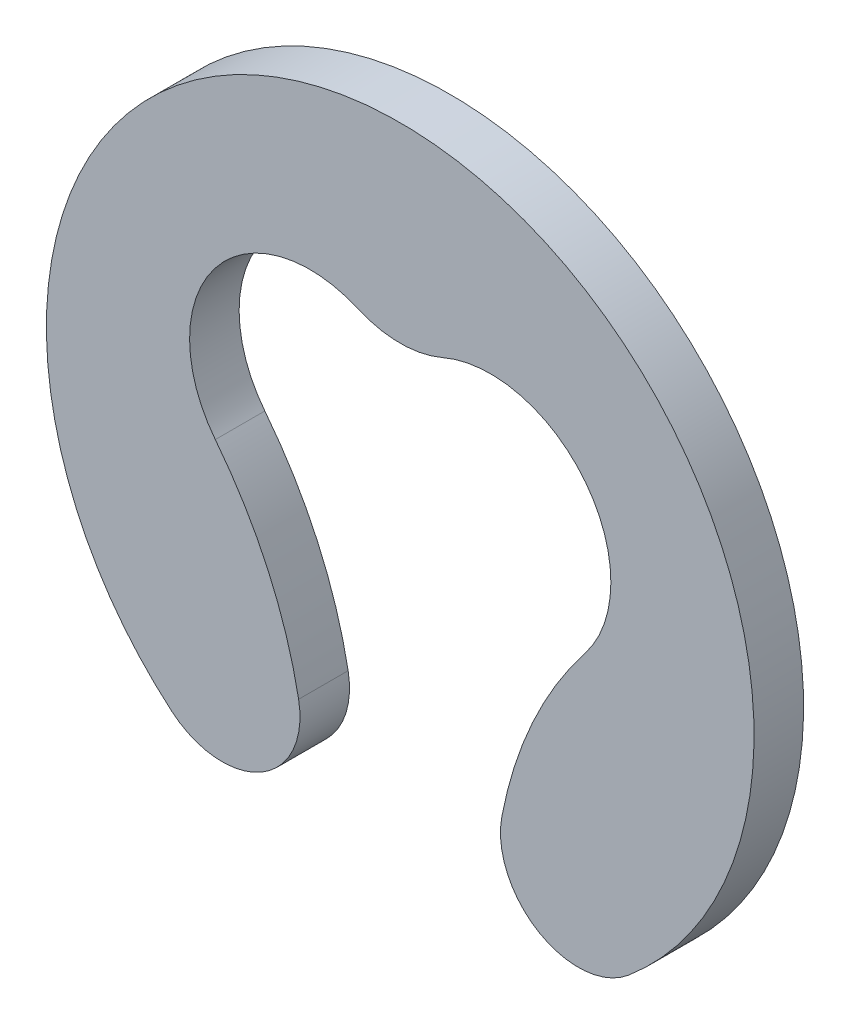
from build123d import *

# Parameters (mm, degrees)
CROQUIS1_R              = 5
SALIENTE_EXTRUIR1_DEPTH = 0.7
CORTAR_EXTRUIR1_REACH   = 2.7
REDONDEO1_R             = 1.1


with BuildPart() as part:
    # Croquis1 → Saliente-Extruir1 (new body)
    with BuildSketch(Plane.XY):
        Circle(CROQUIS1_R)
    extrude(amount=SALIENTE_EXTRUIR1_DEPTH)

    # Croquis2 → Cortar-Extruir1 (cut, up to next)
    with BuildSketch(Plane.XY.offset(0.7), mode=Mode.PRIVATE) as cortar_extruir1_sk1:
        with BuildLine():
            ThreePointArc((-0.598421585, 2.424539493), (0, 2.3), (0.598421585, 2.424539493))
            ThreePointArc((0.598421585, 2.424539493), (2.622160983, 1.904699976), (2.61328938, -0.184719936))
            ThreePointArc((2.61328938, -0.184719936), (1.528064828, -2.366548348), (1.4, -4.8))
            ThreePointArc((1.4, -4.8), (0, -5), (-1.4, -4.8))
            ThreePointArc((-1.4, -4.8), (-1.528064828, -2.366548348), (-2.61328938, -0.184719936))
            ThreePointArc((-2.61328938, -0.184719936), (-2.622160983, 1.904699976), (-0.598421585, 2.424539493))
        make_face()
    cortar_extruir1_tool1 = extrude(cortar_extruir1_sk1.sketch, amount=-CORTAR_EXTRUIR1_REACH, mode=Mode.PRIVATE) & part.part
    add(cortar_extruir1_tool1.solids().sort_by_distance((0, -0.660031, 0.7))[0], mode=Mode.SUBTRACT)

    # Redondeo1
    redondeo1_edges = [part.edges().sort_by_distance(p)[0] for p in [
        (1.4, -4.8, 0.35),
        (-1.4, -4.8, 0.35),
    ]]
    fillet(redondeo1_edges, radius=REDONDEO1_R)


solid = part.part
